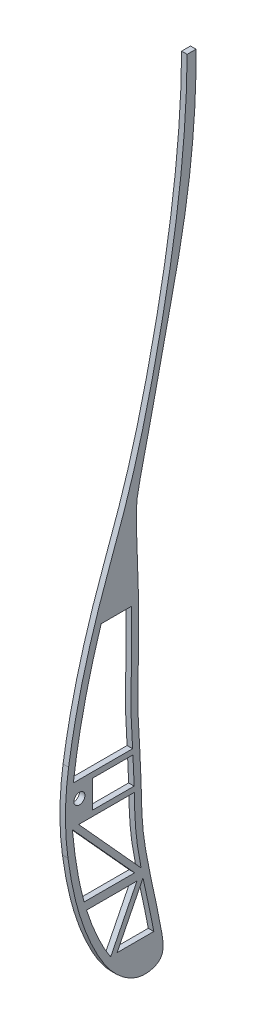
from build123d import *

# Parameters (mm, degrees)
RIB2_R              = 2
BOSS_EXTRUDE5_DEPTH = 2


with BuildPart() as part:
    # rib2 → Boss-Extrude5 (new body)
    with BuildSketch(Plane(origin=(0, 0, 0), x_dir=(0, 0, -1), z_dir=(1, 0, 0))):
        with BuildLine():
            Line((801.906188374, 590.408064711), (805.114959312, 590.408064711))
            add(Edge.make_bspline(
                [(758.760184696, 360.065706417), (759.454511359, 354.912593588), (761.639215144, 342.918031631), (767.602503808, 326.356505877), (776.364446292, 313.183311775), (785.880697371, 308.841980468), (791.313928595, 310.610251685), (793.075385029, 312.987941846), (793.337462447, 316.107743129), (791.041438182, 329.643146103), (787.955992365, 341.196605561), (785.204159751, 359.620713161), (785.453788795, 372.997065253), (783.431517771, 397.430131694), (785.247615348, 420.762517316), (783.053458863, 455.809656019), (784.46944524, 464.386743168), (788.132816832, 479.293540681), (793.242767846, 503.980467438), (802.540056937, 542.60535953), (805.258661067, 572.394099523), (805.114959312, 590.408064711)],
                knots=[0.028705379, 0.028705379, 0.028705379, 0.028705379, 0.059246857, 0.100347506, 0.132199535, 0.149145767, 0.158795903, 0.160733945, 0.167660381, 0.175846517, 0.23440917, 0.246070128, 0.285135768, 0.310616456, 0.385264398, 0.441942427, 0.454032525, 0.506165375, 0.624061376, 0.777474311, 1, 1, 1, 1], degree=3))
            ThreePointArc((758.760184696, 360.065706417), (757.868119496, 374.254747724), (758.997230435, 388.426895834))
            add(Edge.make_bspline(
                [(801.906188374, 590.408064711), (801.696570251, 560.152088887), (794.998763592, 516.43732618), (781.936935882, 464.922101841), (769.954968016, 434.335812649), (762.960296942, 410.299032991), (759.919340123, 394.501457002), (758.997230435, 388.426895834)],
                knots=[0, 0, 0, 0, 0.408822914, 0.598513204, 0.719261824, 0.854060705, 0.937350514, 0.937350514, 0.937350514, 0.937350514], degree=3))
        make_face()
        with Locations((762.916566478, 376.641580619)):
            Circle(RIB2_R, mode=Mode.SUBTRACT)
        with BuildLine():
            Line((782.893255333, 343.385908236), (760.356317877, 368.210879977))
            add(Edge.make_bspline(
                [(760.356317877, 368.210879977), (760.645542865, 365.10832887), (761.297099334, 359.39979898), (762.685561286, 351.207948443), (763.890877386, 346.064289497), (764.603996251, 343.478926304), (764.629795024, 343.385908236)],
                knots=[0.01313003, 0.01313003, 0.01313003, 0.01313003, 0.031626349, 0.047245279, 0.062864209, 0.063447417, 0.063447417, 0.063447417, 0.063447417], degree=3))
            Line((764.629795024, 343.385908236), (782.893255333, 343.385908236))
        make_face(mode=Mode.SUBTRACT)
        with BuildLine():
            Line((785.235370081, 343.762046236), (762.664726398, 368.641580619))
            Line((762.664726398, 368.641580619), (782.775527242, 368.641580619))
            add(Edge.make_bspline(
                [(785.235370081, 343.762046236), (784.91173753, 345.435849463), (784.369480265, 348.412605531), (783.683400446, 352.846020065), (783.09231997, 358.350652793), (782.886598013, 363.619677576), (782.80105443, 367.500970974), (782.775527242, 368.641580619)],
                knots=[0.224345048, 0.224345048, 0.224345048, 0.224345048, 0.234672437, 0.242481902, 0.250291367, 0.265910297, 0.272429812, 0.272429812, 0.272429812, 0.272429812], degree=3))
        make_face(mode=Mode.SUBTRACT)
        with BuildLine():
            Line((783.737403403, 340.385908263), (774.220368213, 321.355424184))
            add(Edge.make_bspline(
                [(765.512588053, 340.385908263), (765.942062452, 339.008160638), (767.225549025, 335.196727707), (769.261685791, 330.291102646), (771.60894792, 325.640152406), (773.096725597, 323.059967565), (774.004343098, 321.674751511), (774.220368213, 321.355424184)],
                knots=[0.069750662, 0.069750662, 0.069750662, 0.069750662, 0.078483139, 0.094102069, 0.101911534, 0.109720999, 0.112105214, 0.112105214, 0.112105214, 0.112105214], degree=3))
            Line((765.512588053, 340.385908263), (783.737403403, 340.385908263))
        make_face(mode=Mode.SUBTRACT)
        with BuildLine():
            Line((767.571939027, 380.641580619), (767.571939027, 370.641580619))
            Line((767.571939027, 370.641580619), (782.729137506, 370.641580619))
            add(Edge.make_bspline(
                [(782.729137506, 370.641580619), (782.706435659, 371.563392329), (782.64381769, 373.84263601), (782.499614968, 377.160810261), (782.352274741, 379.579890207), (782.285482298, 380.641580619)],
                knots=[0.276245485, 0.276245485, 0.276245485, 0.276245485, 0.281529227, 0.289338692, 0.295444604, 0.295444604, 0.295444604, 0.295444604], degree=3))
            Line((782.285482298, 380.641580619), (767.571939027, 380.641580619))
        make_face(mode=Mode.SUBTRACT)
        with BuildLine():
            Line((776.543525523, 321.529397962), (789.845927053, 321.529397962))
            add(Edge.make_bspline(
                [(789.845927053, 321.529397962), (789.814167011, 321.699503823), (789.75042892, 322.038893566), (789.457737754, 323.580698572), (788.929454, 326.240421287), (788.149638114, 329.952624524), (787.332530562, 333.724036883), (786.588165074, 337.157851053), (786.125599329, 339.349407119), (785.929582763, 340.297979166)],
                knots=[0.178917784, 0.178917784, 0.178917784, 0.178917784, 0.179893967, 0.18087015, 0.187815648, 0.195625113, 0.203434578, 0.211244043, 0.217170107, 0.217170107, 0.217170107, 0.217170107], degree=3))
            Line((785.929582763, 340.297979166), (776.543525523, 321.529397962))
        make_face(mode=Mode.SUBTRACT)
        with BuildLine():
            Line((760.713816227, 382.641580619), (782.158524772, 382.641580619))
            add(Edge.make_bspline(
                [(782.158524772, 382.641580619), (782.009801347, 384.984999743), (781.532269832, 392.728796781), (781.601558597, 402.504492042), (781.812144771, 413.028444883), (781.889539879, 420.046613203), (781.856336874, 425.007877782), (781.822920812, 427.030653457), (781.814391399, 427.491820966)],
                knots=[0.299279435, 0.299279435, 0.299279435, 0.299279435, 0.312767087, 0.344004946, 0.359623876, 0.375242806, 0.383052271, 0.385336265, 0.385336265, 0.385336265, 0.385336265], degree=3))
            Line((781.814391399, 427.491820966), (770.786643098, 427.491820966))
            add(Edge.make_bspline(
                [(770.786643098, 427.491820966), (769.467056164, 423.338665257), (766.964736871, 414.770061406), (763.38044978, 399.851527626), (761.525068294, 389.014059476), (760.713816227, 382.641580619)],
                knots=[0.752167527, 0.752167527, 0.752167527, 0.752167527, 0.811772658, 0.874216708, 0.962264248, 0.962264248, 0.962264248, 0.962264248], degree=3))
        make_face(mode=Mode.SUBTRACT)
    extrude(amount=BOSS_EXTRUDE5_DEPTH)


solid = part.part
